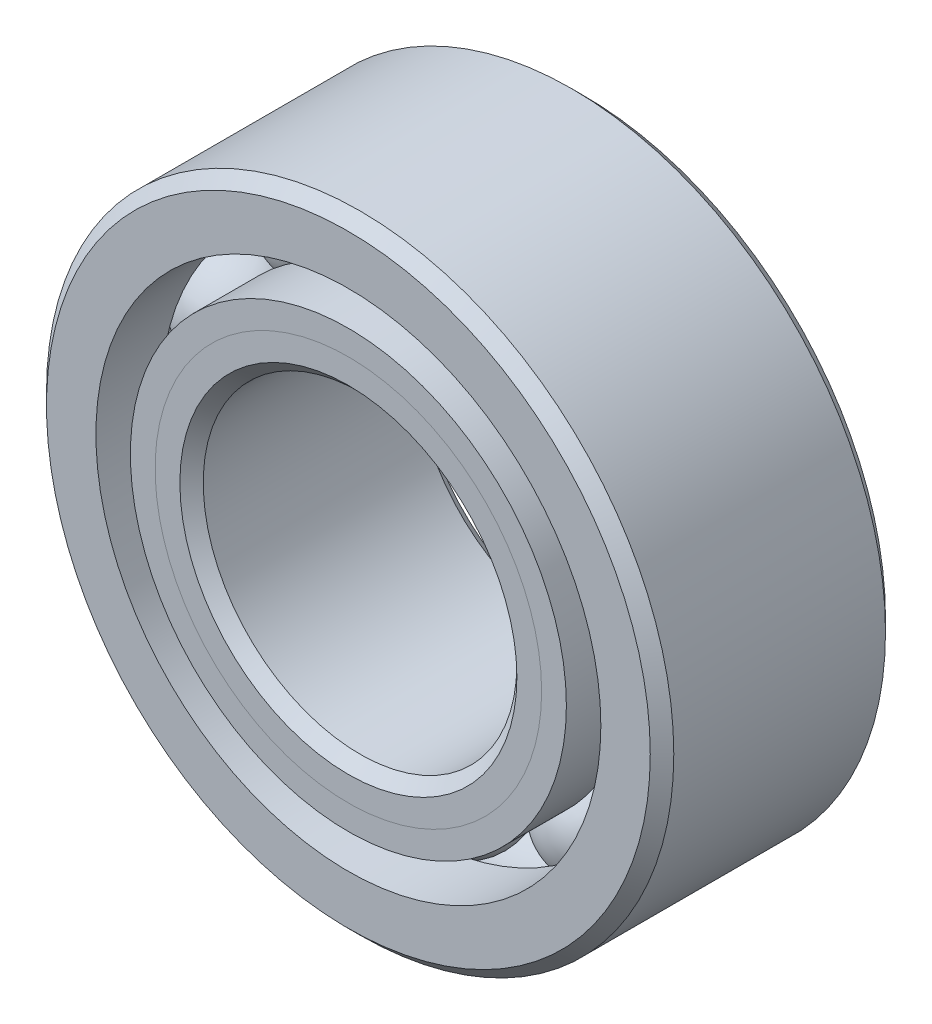
from build123d import *

# Parameters (mm, degrees)
CIRPATTERN1_COUNT = 10


with BuildPart() as part:
    # Sketch1 → Revolve1 (revolve)
    with BuildSketch(Plane(origin=(0, 0, 0), x_dir=(0, 0, -1), z_dir=(1, 0, 0))):
        with BuildLine():
            Line((1.0715625, 3.175), (-1.0715625, 3.175))
            Line((-1.0715625, 3.175), (-1.190625, 3.0559375))
            Line((-1.190625, 3.0559375), (-1.190625, 2.555700549))
            Line((-1.190625, 2.555700549), (-0.529166667, 2.555700549))
            ThreePointArc((-0.529166667, 2.555700549), (0, 2.938430721), (0.529166667, 2.555700549))
            Line((0.529166667, 2.555700549), (1.190625, 2.555700549))
            Line((1.190625, 2.555700549), (1.190625, 3.0559375))
            Line((1.190625, 3.0559375), (1.0715625, 3.175))
        make_face()
    revolve(axis=Axis((0, 0, 1.190625), (0, 0, -1)))


with BuildPart() as body_2:
    # Sketch2 → Revolve2 (revolve)
    with BuildSketch(Plane(origin=(0, 0, 0), x_dir=(0, 0, -1), z_dir=(1, 0, 0))):
        with BuildLine():
            Line((-1.190625, 2.206799451), (-0.529166667, 2.206799451))
            ThreePointArc((-0.529166667, 2.206799451), (-0.32653474, 1.929779714), (0, 1.824069279))
            Line((0, 1.824069279), (0, 1.70578464))
            Line((0, 1.70578464), (-0.940117595, 1.70578464))
            Line((-0.940117595, 1.70578464), (-1.190625, 1.956292045))
            Line((-1.190625, 1.956292045), (-1.190625, 2.206799451))
        make_face()
    revolve(axis=Axis((0, 0, 1.190625), (0, 0, -1)))


with BuildPart() as body_3:
    # Sketch3 → Revolve3 (revolve)
    with BuildSketch(Plane(origin=(0, 0, 0), x_dir=(0, 0, -1), z_dir=(1, 0, 0))):
        with BuildLine():
            Line((-1.190625, 1.956292045), (-0.940117595, 1.70578464))
            Line((-0.940117595, 1.70578464), (0, 1.70578464))
            Line((0, 1.70578464), (0, 1.824069279))
            ThreePointArc((0, 1.824069279), (0.32653474, 1.929779714), (0.529166667, 2.206799451))
            Line((0.529166667, 2.206799451), (1.190625, 2.206799451))
            Line((1.190625, 2.206799451), (1.190625, 1.7065625))
            Line((1.190625, 1.7065625), (1.0715625, 1.5875))
            Line((1.0715625, 1.5875), (-1.07234036, 1.5875))
            Line((-1.07234036, 1.5875), (-1.190625, 1.70578464))
            Line((-1.190625, 1.70578464), (-1.190625, 1.956292045))
        make_face()
    revolve(axis=Axis((0, 0, 1.190625), (0, 0, -1)))


with BuildPart() as body_4:
    # Sketch4 → Revolve4 (revolve)
    with BuildSketch(Plane(origin=(0, 0, 0), x_dir=(0, 0, -1), z_dir=(1, 0, 0))):
        with BuildLine():
            Line((-0.557180721, 2.38125), (0.557180721, 2.38125))
            ThreePointArc((0.557180721, 2.38125), (0, 2.938430721), (-0.557180721, 2.38125))
        make_face()
    revolve(axis=Axis((0, 2.38125, 0.557180721), (0, 0, -1)))


with BuildPart() as cirpattern1_1:
    # CirPattern1: pattern copy
    add(body_4.part.rotate(Axis((0, 0, 0), (0, 0, 1)), 1 * 360 / CIRPATTERN1_COUNT))


with BuildPart() as cirpattern1_2:
    # CirPattern1: pattern copy
    add(body_4.part.rotate(Axis((0, 0, 0), (0, 0, 1)), 2 * 360 / CIRPATTERN1_COUNT))


with BuildPart() as cirpattern1_3:
    # CirPattern1: pattern copy
    add(body_4.part.rotate(Axis((0, 0, 0), (0, 0, 1)), 3 * 360 / CIRPATTERN1_COUNT))


with BuildPart() as cirpattern1_4:
    # CirPattern1: pattern copy
    add(body_4.part.rotate(Axis((0, 0, 0), (0, 0, 1)), 4 * 360 / CIRPATTERN1_COUNT))


with BuildPart() as cirpattern1_5:
    # CirPattern1: pattern copy
    add(body_4.part.rotate(Axis((0, 0, 0), (0, 0, 1)), 5 * 360 / CIRPATTERN1_COUNT))


with BuildPart() as cirpattern1_6:
    # CirPattern1: pattern copy
    add(body_4.part.rotate(Axis((0, 0, 0), (0, 0, 1)), 6 * 360 / CIRPATTERN1_COUNT))


with BuildPart() as cirpattern1_7:
    # CirPattern1: pattern copy
    add(body_4.part.rotate(Axis((0, 0, 0), (0, 0, 1)), 7 * 360 / CIRPATTERN1_COUNT))


with BuildPart() as cirpattern1_8:
    # CirPattern1: pattern copy
    add(body_4.part.rotate(Axis((0, 0, 0), (0, 0, 1)), 8 * 360 / CIRPATTERN1_COUNT))


with BuildPart() as cirpattern1_9:
    # CirPattern1: pattern copy
    add(body_4.part.rotate(Axis((0, 0, 0), (0, 0, 1)), 9 * 360 / CIRPATTERN1_COUNT))


solid = Compound([part.part, body_2.part, body_3.part, body_4.part, cirpattern1_1.part, cirpattern1_2.part, cirpattern1_3.part, cirpattern1_4.part, cirpattern1_5.part, cirpattern1_6.part, cirpattern1_7.part, cirpattern1_8.part, cirpattern1_9.part])
